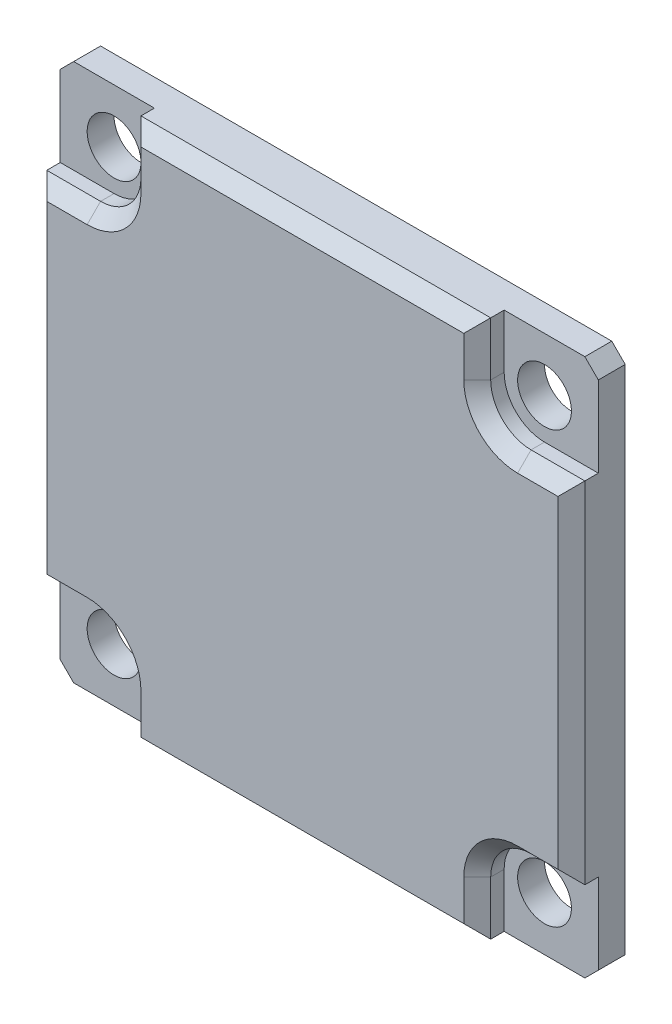
from build123d import *

# Parameters (mm, degrees)
CROQUIS1_W              = 40
CROQUIS1_H              = 40
CROQUIS1_R              = 2
CROQUIS1_R_2            = 17
SALIENTE_EXTRUIR1_DEPTH = 3
CROQUIS2_W              = 40
CROQUIS2_H              = 40
SALIENTE_EXTRUIR2_DEPTH = 1
CORTAR_EXTRUIR1_DEPTH   = 2
CHAFL_N1_SIZE           = 1


with BuildPart() as part:
    # Croquis1 → Saliente-Extruir1 (new body)
    with BuildSketch(Plane.XY):
        Rectangle(CROQUIS1_W, CROQUIS1_H)
        with Locations((-16, -16)):
            Circle(CROQUIS1_R, mode=Mode.SUBTRACT)
        with Locations((16, -16)):
            Circle(CROQUIS1_R, mode=Mode.SUBTRACT)
        with Locations((16, 16)):
            Circle(CROQUIS1_R, mode=Mode.SUBTRACT)
        with Locations((-16, 16)):
            Circle(CROQUIS1_R, mode=Mode.SUBTRACT)
        Circle(CROQUIS1_R_2, mode=Mode.SUBTRACT)
    extrude(amount=SALIENTE_EXTRUIR1_DEPTH)

    # Croquis2 → Saliente-Extruir2 (add)
    with BuildSketch(Plane.XY.offset(3)):
        Rectangle(CROQUIS2_W, CROQUIS2_H)
    extrude(amount=SALIENTE_EXTRUIR2_DEPTH)

    # Croquis3 → Cortar-Extruir1 (cut)
    with BuildSketch(Plane.XY.offset(4)):
        with BuildLine():
            Line((13, 16), (13, 20))
            Line((13, 20), (20, 20))
            Line((20, 20), (20, 13))
            Line((20, 13), (16, 13))
            ThreePointArc((16, 13), (13.878679656, 13.878679656), (13, 16))
        make_face()
        with BuildLine():
            Line((-13, 16), (-13, 20))
            Line((-13, 20), (-20, 20))
            Line((-20, 20), (-20, 13))
            Line((-20, 13), (-16, 13))
            ThreePointArc((-16, 13), (-13.878679656, 13.878679656), (-13, 16))
        make_face()
        with BuildLine():
            Line((16, -13), (20, -13))
            Line((20, -13), (20, -20))
            Line((20, -20), (13, -20))
            Line((13, -20), (13, -16))
            ThreePointArc((13, -16), (13.878679656, -13.878679656), (16, -13))
        make_face()
        with BuildLine():
            Line((-13, -16), (-13, -20))
            Line((-13, -20), (-20, -20))
            Line((-20, -20), (-20, -13))
            Line((-20, -13), (-16, -13))
            ThreePointArc((-16, -13), (-13.878679656, -13.878679656), (-13, -16))
        make_face()
    extrude(amount=-CORTAR_EXTRUIR1_DEPTH, mode=Mode.SUBTRACT)

    # Chaflán1
    chafl_n1_edges = [part.edges().sort_by_distance(p)[0] for p in [
        (-20, 0, 4),
        (0, -20, 4),
        (20, 0, 4),
        (0, 20, 4),
        (20, -20, 1),
        (-20, -20, 1),
        (-20, 20, 1),
        (20, 20, 1),
        (-13.878679656, -13.878679656, 4),
        (-18, -13, 4),
        (-13, -18, 4),
        (13.878679656, -13.878679656, 4),
        (13, -18, 4),
        (18, -13, 4),
        (13.878679656, 13.878679656, 4),
        (18, 13, 4),
        (13, 18, 4),
        (-18, 13, 4),
        (-13.878679656, 13.878679656, 4),
        (-13, 18, 4),
    ]]
    chamfer(chafl_n1_edges, length=CHAFL_N1_SIZE)


solid = part.part
